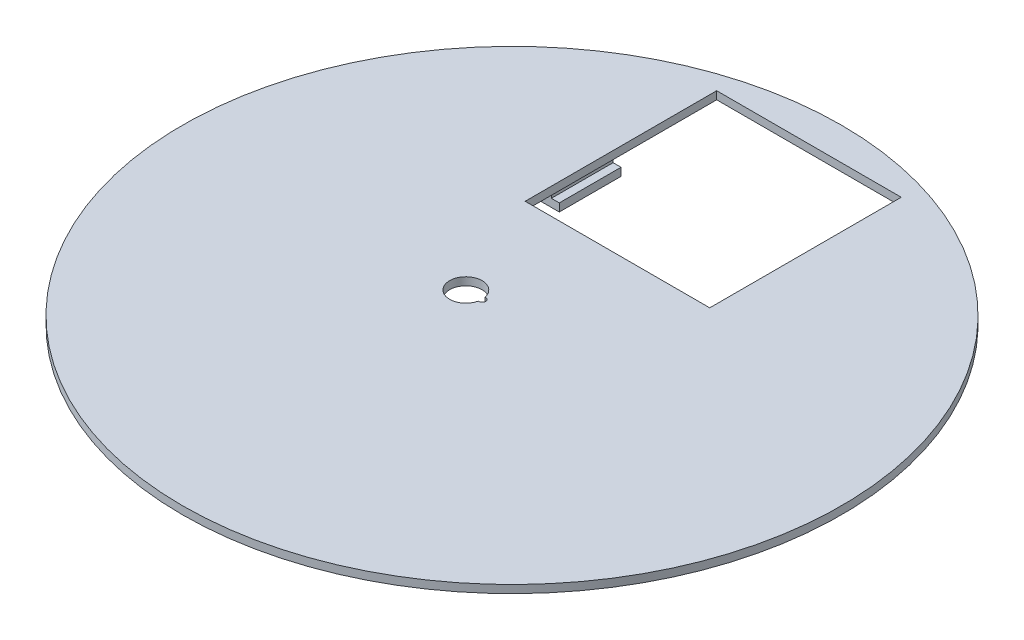
from build123d import *

# Parameters (mm, degrees)
IZIM1_R                     = 125
IZIM1_W                     = 70
IZIM1_H                     = 72.635569235
Y_KSEKLIK_EKSTR_ZYON1_DEPTH = 3
IZIM6_W                     = 4
IZIM6_H                     = 23.415137081
Y_KSEKLIK_EKSTR_ZYON3_DEPTH = 4
Y_KSEKLIK_EKSTR_ZYON4_START = 4
IZIM6_3_W                   = 7
IZIM6_3_H                   = 23.415137081
Y_KSEKLIK_EKSTR_ZYON4_DEPTH = 3
IZIM8_R                     = 2.5
Y_KSEKLIK_EKSTR_ZYON5_DEPTH = 3
Y_KSEKLIK_EKSTR_ZYON6_START = 3
IZIM8_4_R                   = 4.5
Y_KSEKLIK_EKSTR_ZYON6_DEPTH = 3
KES_EKSTR_ZYON1_DEPTH       = 4


with BuildPart() as part:
    # Çizim1 → Yükseklik-Ekstrüzyon1 (new body)
    with BuildSketch(Plane(origin=(0, 0, 0), x_dir=(1, 0, 0), z_dir=(0, 1, 0))):
        Circle(IZIM1_R)
        with Locations((0, 76.317784617)):
            Rectangle(IZIM1_W, IZIM1_H, mode=Mode.SUBTRACT)
    extrude(amount=Y_KSEKLIK_EKSTR_ZYON1_DEPTH)

    # Çizim6 → Yükseklik-Ekstrüzyon3 (add)
    with BuildSketch(Plane.XZ):
        with Locations((-40, -64.642786203)):
            Rectangle(IZIM6_W, IZIM6_H)
    extrude(amount=Y_KSEKLIK_EKSTR_ZYON3_DEPTH)

    # Çizim6<3> → Yükseklik-Ekstrüzyon4 (add)
    with BuildSketch(Plane.XZ.offset(Y_KSEKLIK_EKSTR_ZYON4_START)):
        with Locations((-38.5, -64.642786203)):
            Rectangle(IZIM6_3_W, IZIM6_3_H)
    extrude(amount=Y_KSEKLIK_EKSTR_ZYON4_DEPTH)

    # Çizim8 → Yükseklik-Ekstrüzyon5 (add)
    with BuildSketch(Plane.XZ):
        with Locations((4.318604625, -2.102613205)):
            Circle(IZIM8_R)
    extrude(amount=Y_KSEKLIK_EKSTR_ZYON5_DEPTH)

    # Çizim8<4> → Yükseklik-Ekstrüzyon6 (add)
    with BuildSketch(Plane.XZ.offset(Y_KSEKLIK_EKSTR_ZYON6_START)):
        with Locations((4.318604625, -2.102613205)):
            Circle(IZIM8_4_R)
    extrude(amount=Y_KSEKLIK_EKSTR_ZYON6_DEPTH)

    # Çizim10 → Kes-Ekstrüzyon1 (cut, through all)
    with BuildSketch(Plane.XZ):
        with BuildLine():
            ThreePointArc((-11.097827728, 1.63805679), (-23.268577728, 0.38383614), (-11.097827728, -0.870384509))
            ThreePointArc((-11.097827728, -0.870384509), (-9.593577728, 0.38383614), (-11.097827728, 1.63805679))
        make_face()
    extrude(amount=-KES_EKSTR_ZYON1_DEPTH, mode=Mode.SUBTRACT)


solid = part.part
